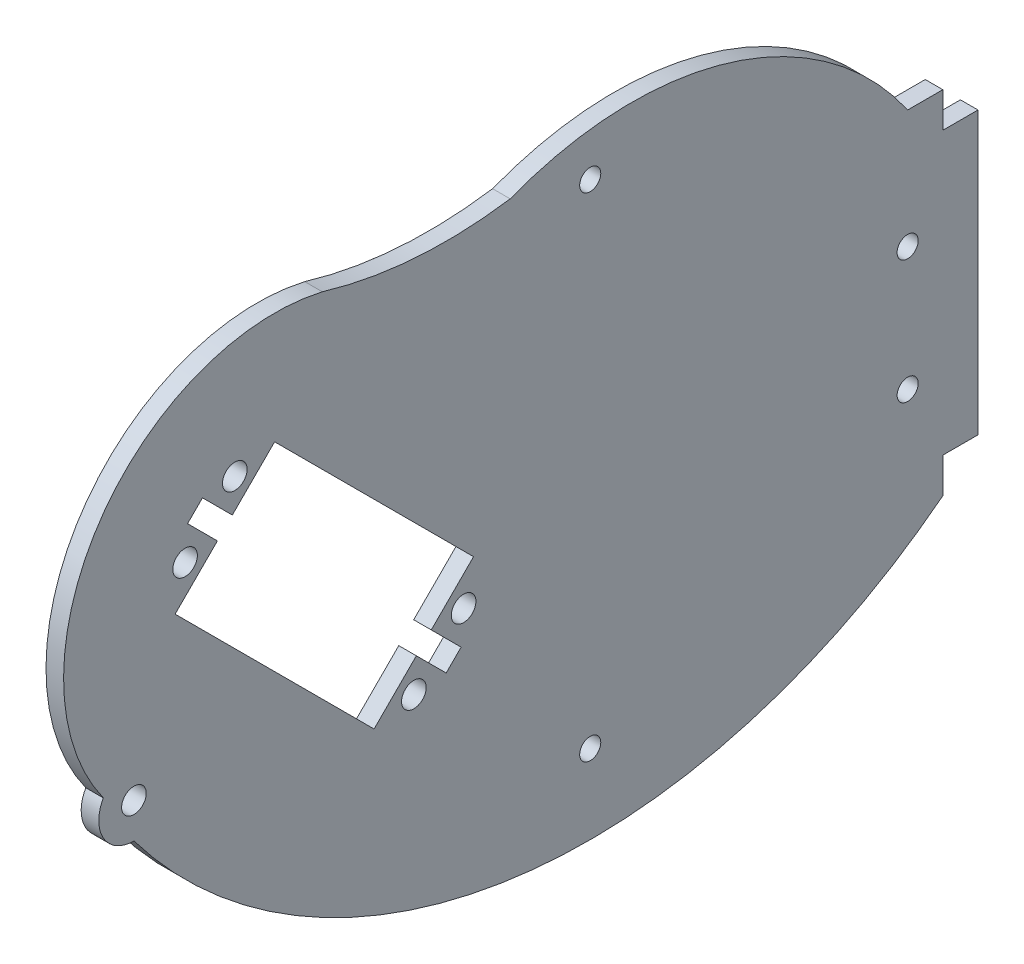
from build123d import *

# Parameters (mm, degrees)
CROQUIS1_R              = 1.75
CROQUIS1_R_2            = 1.5
SALIENTE_EXTRUIR1_DEPTH = 2.5


with BuildPart() as part:
    # Croquis1 → Saliente-Extruir1 (new body)
    with BuildSketch(Plane(origin=(0, 0, 0), x_dir=(0, 0, -1), z_dir=(1, 0, 0))):
        with BuildLine():
            Line((95, 10), (90, 10))
            ThreePointArc((90, 10), (64.751798433, 28.463425825), (33.494108419, 27.311648705))
            ThreePointArc((33.494108419, 27.311648705), (20.033827629, 26.787261985), (6.785305839, 29.222587577))
            ThreePointArc((6.785305839, 29.222587577), (-24.970289012, 16.62782808), (-24.346472536, -17.528527464))
            ThreePointArc((-24.346472536, -17.528527464), (-24.321884003, -22.514223272), (-20, -25))
            ThreePointArc((-20, -25), (34.355278896, -56.609528466), (95, -40))
            Line((95, -40), (95, -35))
            Line((95, -35), (100, -35))
            Line((100, -35), (100, 5))
            Line((100, 5), (95, 5))
            Line((95, 5), (95, 10))
        make_face()
        with Locations((-12.730077402, 5.654698909)):
            Circle(CROQUIS1_R, mode=Mode.SUBTRACT)
        with Locations((-5.658477353, 12.726298958)):
            Circle(CROQUIS1_R, mode=Mode.SUBTRACT)
        with Locations((26.870057685, -19.798989873)):
            Circle(CROQUIS1_R, mode=Mode.SUBTRACT)
        with Locations((19.797157185, -26.871890373)):
            Circle(CROQUIS1_R, mode=Mode.SUBTRACT)
        with Locations((-20, -20)):
            Circle(CROQUIS1_R, mode=Mode.SUBTRACT)
        with Locations((90, -6.821183735)):
            Circle(CROQUIS1_R_2, mode=Mode.SUBTRACT)
        with Locations((90, -24.395183951)):
            Circle(CROQUIS1_R_2, mode=Mode.SUBTRACT)
        with Locations((44.87119885, -46.048776814)):
            Circle(CROQUIS1_R_2, mode=Mode.SUBTRACT)
        with Locations((44.87119885, 24.012524519)):
            Circle(CROQUIS1_R_2, mode=Mode.SUBTRACT)
        Polygon((-14.142135624, 0), (14.142135624, -28.284271247), (20.150710576, -22.275696296), (24.393351263, -26.518336983), (26.516504294, -24.395183951), (22.273863607, -20.152543264), (28.284271247, -14.142135624), (0, 14.142135624), (-6.01040764, 8.131727984), (-10.253048327, 12.374368671), (-12.374368671, 10.253048327), (-8.131727984, 6.01040764), align=None, mode=Mode.SUBTRACT)
    extrude(amount=SALIENTE_EXTRUIR1_DEPTH)


solid = part.part
